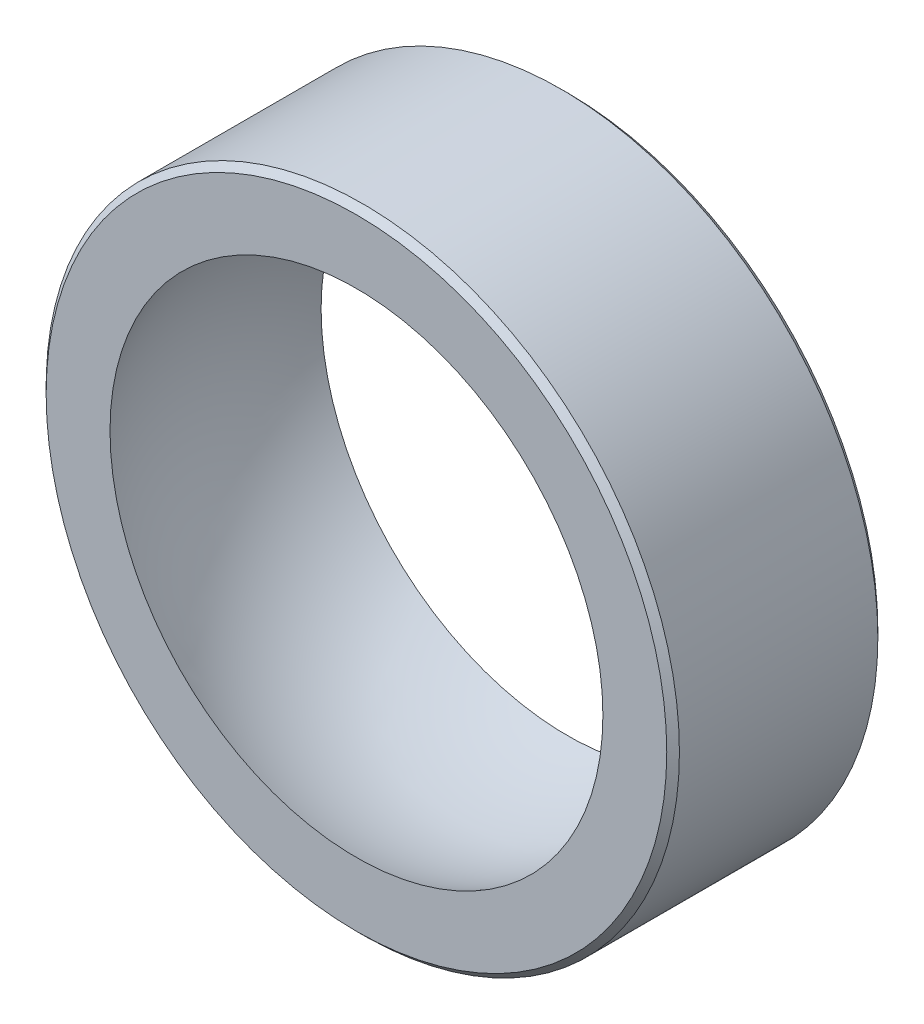
from build123d import *

# Parameters (mm, degrees)
EXTRUDE1_START = -5
SKETCH1_R      = 15
SKETCH1_R_2    = 7.95
EXTRUDE1_DEPTH = 10
CHAMFER1_SIZE  = 0.3


with BuildPart() as part:
    # Sketch1 → Extrude1 (new body)
    with BuildSketch(Plane.XY.offset(EXTRUDE1_START)):
        Circle(SKETCH1_R)
        Circle(SKETCH1_R_2, mode=Mode.SUBTRACT)
    extrude(amount=EXTRUDE1_DEPTH)

    # Chamfer1
    chamfer1_edges = [part.edges().sort_by_distance(p)[0] for p in [
        (-15, 0, -5),
        (-15, 0, 5),
    ]]
    chamfer(chamfer1_edges, length=CHAMFER1_SIZE)

    # Sketch2 → Revolve1 (revolve)
    with BuildSketch(Plane(origin=(0, 0, 0), x_dir=(0, 0, -1), z_dir=(1, 0, 0))):
        with BuildLine():
            Line((7, 3), (-7, 3))
            Line((-7, 3), (-7, 10.596697599))
            ThreePointArc((-7, 10.596697599), (0, 12.7), (7, 10.596697599))
            Line((7, 10.596697599), (7, 3))
        make_face()
    revolve(axis=Axis((0, 0, -11.466432169), (0, 0, 1)))

    # Sketch2_2 → Cut-Revolve1 (revolve, cut)
    with BuildSketch(Plane(origin=(0, 0, 0), x_dir=(0, 0, -1), z_dir=(1, 0, 0))):
        with BuildLine():
            Line((7, 3), (-7, 3))
            Line((-7, 3), (-7, 10.596697599))
            ThreePointArc((-7, 10.596697599), (0, 12.7), (7, 10.596697599))
            Line((7, 10.596697599), (7, 3))
        make_face()
    revolve(axis=Axis((0, 0, -11.466432169), (0, 0, 1)), mode=Mode.SUBTRACT)


solid = part.part
